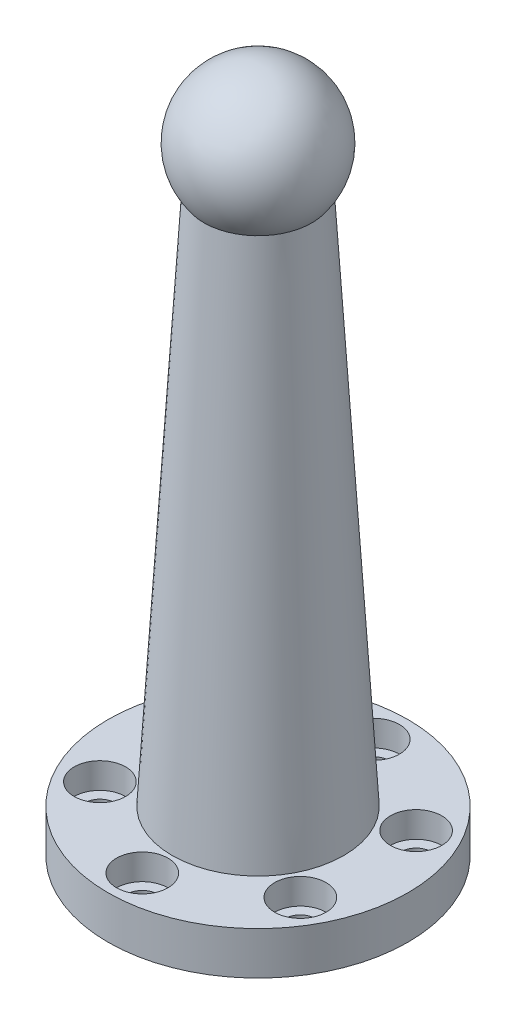
from build123d import *

# Parameters (mm, degrees)
SKETCH_1_R          = 17.5
SKETCH_1_R_2        = 1.75
EXTRUDE_1_DEPTH     = 5
SKETCH_2_R          = 3
CUT_EXTRUDE_1_DEPTH = 3
SKETCH_3_R          = 10
SKETCH_6_R          = 6


with BuildPart() as part:
    # 草图1 → 凸台-拉伸1 (new body)
    with BuildSketch(Plane(origin=(0, 0, 0), x_dir=(1, 0, 0), z_dir=(0, 1, 0))):
        Circle(SKETCH_1_R)
        with Locations((0, 13.5)):
            Circle(SKETCH_1_R_2, mode=Mode.SUBTRACT)
        with Locations((11.691342951, 6.75)):
            Circle(SKETCH_1_R_2, mode=Mode.SUBTRACT)
        with Locations((11.691342951, -6.75)):
            Circle(SKETCH_1_R_2, mode=Mode.SUBTRACT)
        with Locations((0, -13.5)):
            Circle(SKETCH_1_R_2, mode=Mode.SUBTRACT)
        with Locations((-11.691342951, -6.75)):
            Circle(SKETCH_1_R_2, mode=Mode.SUBTRACT)
        with Locations((-11.691342951, 6.75)):
            Circle(SKETCH_1_R_2, mode=Mode.SUBTRACT)
    extrude(amount=EXTRUDE_1_DEPTH)

    # 草图2 → 切除-拉伸1 (cut)
    with BuildSketch(Plane(origin=(0, 5, 0), x_dir=(1, 0, 0), z_dir=(0, 1, 0))):
        with Locations((0, 13.5)):
            Circle(SKETCH_2_R)
        with Locations((11.691342951, 6.75)):
            Circle(SKETCH_2_R)
        with Locations((11.691342951, -6.75)):
            Circle(SKETCH_2_R)
        with Locations((0, -13.5)):
            Circle(SKETCH_2_R)
        with Locations((-11.691342951, -6.75)):
            Circle(SKETCH_2_R)
        with Locations((-11.691342951, 6.75)):
            Circle(SKETCH_2_R)
    extrude(amount=-CUT_EXTRUDE_1_DEPTH, mode=Mode.SUBTRACT)

    # 草图3 → 放样1 section 0
    with BuildSketch(Plane(origin=(0, 5, 0), x_dir=(1, 0, 0), z_dir=(0, 1, 0))):
        Circle(SKETCH_3_R)
    # 草图6 → 放样1 section 1
    with BuildSketch(Plane(origin=(0, 72, 0), x_dir=(1, 0, 0), z_dir=(0, 1, 0))):
        Circle(SKETCH_6_R)
    loft()

    # 草图7 → 旋转7 (revolve)
    with BuildSketch(Plane(origin=(0, 72, 0), x_dir=(1, 0, 0), z_dir=(0, 1, 0))):
        with BuildLine():
            Line((-8, 0), (8, 0))
            ThreePointArc((8, 0), (0, 8), (-8, 0))
        make_face()
    revolve(axis=Axis((-8, 72, 0), (1, 0, 0)))


solid = part.part
